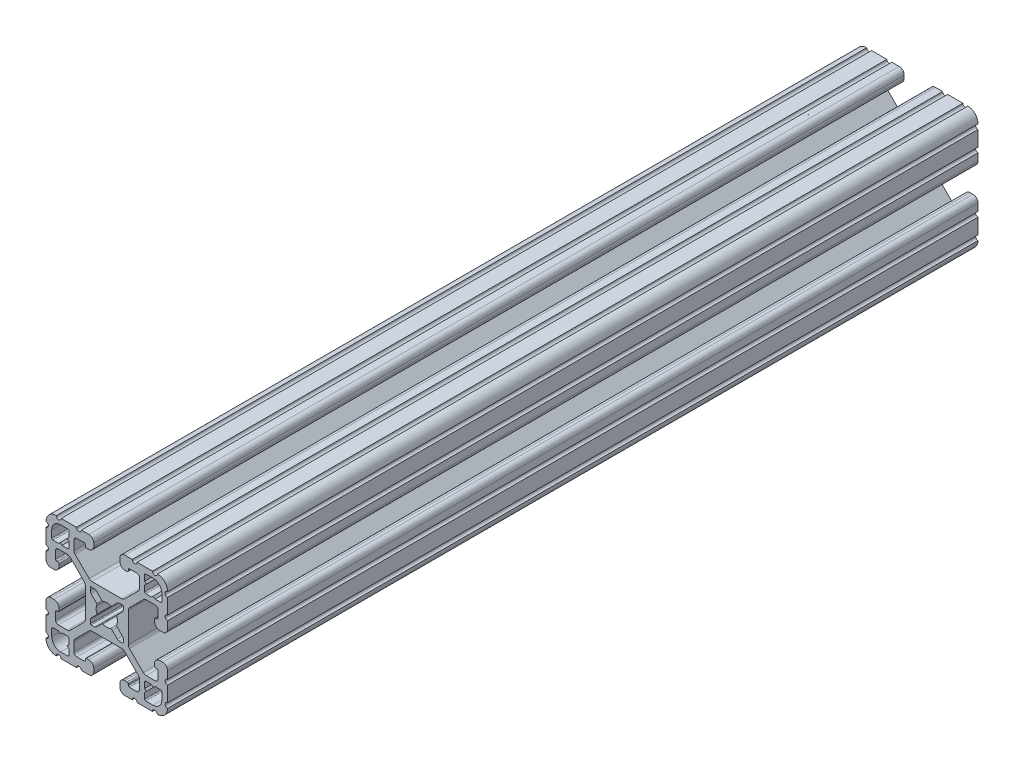
from build123d import *

# Parameters (mm, degrees)
EXTRUDE1_DEPTH = 254


with BuildPart() as part:
    # Sketch1 → Extrude1 (new body)
    with BuildSketch(Plane.XY):
        with BuildLine():
            Line((6.349777007, -14.984831919), (5.653061318, -14.984831848))
            ThreePointArc((5.653061318, -14.984831848), (4.539002167, -15.446080098), (4.077754017, -16.560139291))
            Line((4.077754017, -16.560139291), (4.077753935, -17.474692556))
            ThreePointArc((4.077753935, -17.474692556), (4.539002158, -18.588751741), (5.653061362, -19.049999918))
            Line((5.653061362, -19.049999918), (7.975599859, -19.05))
            ThreePointArc((7.975599859, -19.05), (8.737599929, -18.288), (9.4996, -19.05))
            Line((9.4996, -19.05), (14.298091988, -19.05))
            ThreePointArc((14.298091988, -19.05), (15.05987163, -18.288000032), (15.822092002, -19.049559142))
            ThreePointArc((15.822092002, -19.049559142), (18.110316678, -18.129769245), (19.049898398, -15.849599993))
            ThreePointArc((19.049898398, -15.849599993), (18.288000002, -15.087549199), (19.05, -14.3256))
            Line((19.05, -14.3256), (19.05, -9.499600141))
            ThreePointArc((19.05, -9.499600141), (18.288, -8.737600071), (19.05, -7.9756))
            Line((19.05, -7.9756), (19.05, -5.653061359))
            ThreePointArc((19.05, -5.653061359), (18.588751763, -4.53900218), (17.474692553, -4.077754017))
            Line((17.474692553, -4.077754017), (16.560139293, -4.077753935))
            ThreePointArc((16.560139293, -4.077753935), (15.446080122, -4.539002143), (14.98483193, -5.653061321))
            Line((14.98483193, -5.653061321), (14.984831848, -6.349776986))
            ThreePointArc((14.984831848, -6.349776986), (15.096428348, -6.619420887), (15.366075744, -6.731008942))
            Line((15.366075744, -6.731008942), (15.696937609, -6.730998691))
            ThreePointArc((15.696937609, -6.730998691), (15.966583472, -6.842585282), (16.078181438, -7.112226438))
            Line((16.078181438, -7.112226438), (16.078207121, -9.396837814))
            ThreePointArc((16.078207121, -9.396837814), (15.817838504, -10.026619018), (15.188068118, -10.287013801))
            Line((15.188068118, -10.287013801), (12.352560476, -10.287103022))
            ThreePointArc((12.352560476, -10.287103022), (11.865894357, -10.190173629), (11.453520834, -9.914153164))
            Line((11.453520834, -9.914153164), (7.114725376, -5.565926641))
            ThreePointArc((7.114725376, -5.565926641), (6.840134749, -5.154247475), (6.7437254, -4.668876499))
            Line((6.7437254, -4.668876499), (6.7437254, 4.641368628))
            ThreePointArc((6.7437254, 4.641368628), (6.840134749, 5.126739605), (7.114725376, 5.53841877))
            Line((7.114725376, 5.53841877), (11.480968187, 9.914152308))
            ThreePointArc((11.480968187, 9.914152308), (11.89334171, 10.190172773), (12.380007829, 10.287102166))
            Line((12.380007829, 10.287102166), (15.188068116, 10.287014567))
            ThreePointArc((15.188068116, 10.287014567), (15.817838279, 10.026619243), (16.078206356, 9.396837815))
            Line((16.078206356, 9.396837815), (16.078181509, 7.1122265))
            ThreePointArc((16.078181509, 7.1122265), (15.966583514, 6.842585324), (15.696937607, 6.730998762))
            Line((15.696937607, 6.730998762), (15.366075744, 6.731009012))
            ThreePointArc((15.366075744, 6.731009012), (15.096428376, 6.619420915), (14.984831919, 6.349777007))
            Line((14.984831919, 6.349777007), (14.984831848, 5.653061318))
            ThreePointArc((14.984831848, 5.653061318), (15.446080098, 4.539002167), (16.560139291, 4.077754017))
            Line((16.560139291, 4.077754017), (17.474692556, 4.077753935))
            ThreePointArc((17.474692556, 4.077753935), (18.588751741, 4.539002158), (19.049999918, 5.653061362))
            Line((19.049999918, 5.653061362), (19.05, 7.975599859))
            ThreePointArc((19.05, 7.975599859), (18.288, 8.737599929), (19.05, 9.4996))
            Line((19.05, 9.4996), (19.05, 14.298091988))
            ThreePointArc((19.05, 14.298091988), (18.288000032, 15.05987163), (19.049559142, 15.822092002))
            ThreePointArc((19.049559142, 15.822092002), (18.129769245, 18.110316678), (15.849599993, 19.049898398))
            ThreePointArc((15.849599993, 19.049898398), (15.087549199, 18.288000002), (14.3256, 19.05))
            Line((14.3256, 19.05), (9.499600141, 19.05))
            ThreePointArc((9.499600141, 19.05), (8.737600071, 18.288), (7.9756, 19.05))
            Line((7.9756, 19.05), (5.653061359, 19.05))
            ThreePointArc((5.653061359, 19.05), (4.53900218, 18.588751763), (4.077754017, 17.474692553))
            Line((4.077754017, 17.474692553), (4.077753935, 16.560139293))
            ThreePointArc((4.077753935, 16.560139293), (4.539002143, 15.446080122), (5.653061321, 14.98483193))
            Line((5.653061321, 14.98483193), (6.349776986, 14.984831848))
            ThreePointArc((6.349776986, 14.984831848), (6.619420887, 15.096428348), (6.731008942, 15.366075744))
            Line((6.731008942, 15.366075744), (6.730998691, 15.696937609))
            ThreePointArc((6.730998691, 15.696937609), (6.842585282, 15.966583472), (7.112226438, 16.078181438))
            Line((7.112226438, 16.078181438), (9.396837814, 16.078207121))
            ThreePointArc((9.396837814, 16.078207121), (10.026619018, 15.817838504), (10.287013801, 15.188068118))
            Line((10.287013801, 15.188068118), (10.287103022, 12.352560476))
            ThreePointArc((10.287103022, 12.352560476), (10.190173629, 11.865894357), (9.914153164, 11.453520834))
            Line((9.914153164, 11.453520834), (5.565926641, 7.114725376))
            ThreePointArc((5.565926641, 7.114725376), (5.154247475, 6.840134749), (4.668876499, 6.7437254))
            Line((4.668876499, 6.7437254), (-4.641368628, 6.7437254))
            ThreePointArc((-4.641368628, 6.7437254), (-5.126739605, 6.840134749), (-5.53841877, 7.114725376))
            Line((-5.53841877, 7.114725376), (-9.914152308, 11.480968187))
            ThreePointArc((-9.914152308, 11.480968187), (-10.190172773, 11.89334171), (-10.287102166, 12.380007829))
            Line((-10.287102166, 12.380007829), (-10.287014567, 15.188068116))
            ThreePointArc((-10.287014567, 15.188068116), (-10.026619243, 15.817838279), (-9.396837815, 16.078206356))
            Line((-9.396837815, 16.078206356), (-7.1122265, 16.078181509))
            ThreePointArc((-7.1122265, 16.078181509), (-6.842585324, 15.966583514), (-6.730998762, 15.696937607))
            Line((-6.730998762, 15.696937607), (-6.731008942, 15.366075744))
            ThreePointArc((-6.731008942, 15.366075744), (-6.619420905, 15.096428366), (-6.349777007, 14.984831919))
            Line((-6.349777007, 14.984831919), (-5.653061318, 14.984831848))
            ThreePointArc((-5.653061318, 14.984831848), (-4.539002167, 15.446080098), (-4.077754017, 16.560139291))
            Line((-4.077754017, 16.560139291), (-4.077753935, 17.474692556))
            ThreePointArc((-4.077753935, 17.474692556), (-4.539002158, 18.588751741), (-5.653061362, 19.049999918))
            Line((-5.653061362, 19.049999918), (-7.975599859, 19.05))
            ThreePointArc((-7.975599859, 19.05), (-8.737599929, 18.288), (-9.4996, 19.05))
            Line((-9.4996, 19.05), (-14.298091988, 19.05))
            ThreePointArc((-14.298091988, 19.05), (-15.05987163, 18.288000032), (-15.822092002, 19.049559142))
            ThreePointArc((-15.822092002, 19.049559142), (-18.110316678, 18.129769245), (-19.049898398, 15.849599993))
            ThreePointArc((-19.049898398, 15.849599993), (-18.288000002, 15.087549199), (-19.05, 14.3256))
            Line((-19.05, 14.3256), (-19.05, 9.499600141))
            ThreePointArc((-19.05, 9.499600141), (-18.288, 8.737600071), (-19.05, 7.9756))
            Line((-19.05, 7.9756), (-19.05, 5.653061359))
            ThreePointArc((-19.05, 5.653061359), (-18.588751763, 4.53900218), (-17.474692553, 4.077754017))
            Line((-17.474692553, 4.077754017), (-16.560139293, 4.077753935))
            ThreePointArc((-16.560139293, 4.077753935), (-15.446080122, 4.539002143), (-14.98483193, 5.653061321))
            Line((-14.98483193, 5.653061321), (-14.984831848, 6.349776986))
            ThreePointArc((-14.984831848, 6.349776986), (-15.096428348, 6.619420887), (-15.366075744, 6.731008942))
            Line((-15.366075744, 6.731008942), (-15.696937609, 6.730998691))
            ThreePointArc((-15.696937609, 6.730998691), (-15.966583472, 6.842585283), (-16.078181438, 7.112226438))
            Line((-16.078181438, 7.112226438), (-16.078207121, 9.396837814))
            ThreePointArc((-16.078207121, 9.396837814), (-15.817838504, 10.026619018), (-15.188068118, 10.287013802))
            Line((-15.188068118, 10.287013802), (-12.352560476, 10.287103022))
            ThreePointArc((-12.352560476, 10.287103022), (-11.865894357, 10.190173629), (-11.453520834, 9.914153164))
            Line((-11.453520834, 9.914153164), (-7.114725376, 5.565926641))
            ThreePointArc((-7.114725376, 5.565926641), (-6.840134749, 5.154247475), (-6.7437254, 4.668876499))
            Line((-6.7437254, 4.668876499), (-6.7437254, -4.641368628))
            ThreePointArc((-6.7437254, -4.641368628), (-6.840134749, -5.126739605), (-7.114725376, -5.53841877))
            Line((-7.114725376, -5.53841877), (-11.480968187, -9.914152308))
            ThreePointArc((-11.480968187, -9.914152308), (-11.89334171, -10.190172773), (-12.380007829, -10.287102166))
            Line((-12.380007829, -10.287102166), (-15.188068116, -10.287014567))
            ThreePointArc((-15.188068116, -10.287014567), (-15.817838279, -10.026619243), (-16.078206356, -9.396837815))
            Line((-16.078206356, -9.396837815), (-16.078181509, -7.1122265))
            ThreePointArc((-16.078181509, -7.1122265), (-15.966583514, -6.842585324), (-15.696937607, -6.730998762))
            Line((-15.696937607, -6.730998762), (-15.366075744, -6.731009012))
            ThreePointArc((-15.366075744, -6.731009012), (-15.096428376, -6.619420915), (-14.984831919, -6.349777007))
            Line((-14.984831919, -6.349777007), (-14.984831848, -5.653061318))
            ThreePointArc((-14.984831848, -5.653061318), (-15.446080098, -4.539002167), (-16.560139291, -4.077754017))
            Line((-16.560139291, -4.077754017), (-17.474692556, -4.077753935))
            ThreePointArc((-17.474692556, -4.077753935), (-18.588751741, -4.539002158), (-19.049999918, -5.653061362))
            Line((-19.049999918, -5.653061362), (-19.05, -7.975599859))
            ThreePointArc((-19.05, -7.975599859), (-18.288, -8.737599929), (-19.05, -9.4996))
            Line((-19.05, -9.4996), (-19.05, -14.298091988))
            ThreePointArc((-19.05, -14.298091988), (-18.288000032, -15.05987163), (-19.049559142, -15.822092002))
            ThreePointArc((-19.049559142, -15.822092002), (-18.129769245, -18.110316678), (-15.849599993, -19.049898398))
            ThreePointArc((-15.849599993, -19.049898398), (-15.087549199, -18.288000002), (-14.3256, -19.05))
            Line((-14.3256, -19.05), (-9.499600141, -19.05))
            ThreePointArc((-9.499600141, -19.05), (-8.737600071, -18.288), (-7.9756, -19.05))
            Line((-7.9756, -19.05), (-5.653061359, -19.05))
            ThreePointArc((-5.653061359, -19.05), (-4.53900218, -18.588751763), (-4.077754017, -17.474692553))
            Line((-4.077754017, -17.474692553), (-4.077753935, -16.560139293))
            ThreePointArc((-4.077753935, -16.560139293), (-4.539002143, -15.446080122), (-5.653061321, -14.98483193))
            Line((-5.653061321, -14.98483193), (-6.349776986, -14.984831848))
            ThreePointArc((-6.349776986, -14.984831848), (-6.619420887, -15.096428348), (-6.731008942, -15.366075744))
            Line((-6.731008942, -15.366075744), (-6.730998691, -15.696937609))
            ThreePointArc((-6.730998691, -15.696937609), (-6.842585282, -15.966583472), (-7.112226438, -16.078181438))
            Line((-7.112226438, -16.078181438), (-9.396837814, -16.078207121))
            ThreePointArc((-9.396837814, -16.078207121), (-10.026619018, -15.817838504), (-10.287013801, -15.188068118))
            Line((-10.287013801, -15.188068118), (-10.287103022, -12.352560476))
            ThreePointArc((-10.287103022, -12.352560476), (-10.190173629, -11.865894357), (-9.914153164, -11.453520834))
            Line((-9.914153164, -11.453520834), (-5.565926641, -7.114725376))
            ThreePointArc((-5.565926641, -7.114725376), (-5.154247475, -6.840134749), (-4.668876499, -6.7437254))
            Line((-4.668876499, -6.7437254), (4.641368628, -6.7437254))
            ThreePointArc((4.641368628, -6.7437254), (5.126739605, -6.840134749), (5.53841877, -7.114725376))
            Line((5.53841877, -7.114725376), (9.914152308, -11.480968187))
            ThreePointArc((9.914152308, -11.480968187), (10.190172773, -11.89334171), (10.287102166, -12.380007829))
            Line((10.287102166, -12.380007829), (10.287014567, -15.188068116))
            ThreePointArc((10.287014567, -15.188068116), (10.026619243, -15.817838279), (9.396837815, -16.078206356))
            Line((9.396837815, -16.078206356), (7.1122265, -16.078181509))
            ThreePointArc((7.1122265, -16.078181509), (6.842585324, -15.966583514), (6.730998762, -15.696937607))
            Line((6.730998762, -15.696937607), (6.731008942, -15.366075744))
            ThreePointArc((6.731008942, -15.366075744), (6.619420905, -15.096428366), (6.349777007, -14.984831919))
        make_face()
        with BuildLine():
            Line((1.582347442, 3.198793543), (3.292097227, 4.908543328))
            ThreePointArc((3.292097227, 4.908543328), (3.580509584, 5.101254304), (3.920715155, 5.1689254))
            Line((3.920715155, 5.1689254), (4.9149254, 5.1689254))
            ThreePointArc((4.9149254, 5.1689254), (5.094530522, 5.094530522), (5.1689254, 4.9149254))
            Line((5.1689254, 4.9149254), (5.1689254, 3.920715155))
            ThreePointArc((5.1689254, 3.920715155), (5.101254304, 3.580509584), (4.908543328, 3.292097227))
            Line((4.908543328, 3.292097227), (3.198793543, 1.582347442))
            ThreePointArc((3.198793543, 1.582347442), (3.095711236, 1.393016011), (3.111879183, 1.178048687))
            ThreePointArc((3.111879183, 1.178048687), (3.3274, 0), (3.111879183, -1.178048687))
            ThreePointArc((3.111879183, -1.178048687), (3.095711236, -1.393016011), (3.198793543, -1.582347442))
            Line((3.198793543, -1.582347442), (4.908543328, -3.292097227))
            ThreePointArc((4.908543328, -3.292097227), (5.101254304, -3.580509584), (5.1689254, -3.920715155))
            Line((5.1689254, -3.920715155), (5.1689254, -4.9149254))
            ThreePointArc((5.1689254, -4.9149254), (5.094530522, -5.094530522), (4.9149254, -5.1689254))
            Line((4.9149254, -5.1689254), (3.920715155, -5.1689254))
            ThreePointArc((3.920715155, -5.1689254), (3.580509584, -5.101254304), (3.292097227, -4.908543328))
            Line((3.292097227, -4.908543328), (1.582347442, -3.198793543))
            ThreePointArc((1.582347442, -3.198793543), (1.393016011, -3.095711236), (1.178048687, -3.111879183))
            ThreePointArc((1.178048687, -3.111879183), (0, -3.3274), (-1.178048687, -3.111879183))
            ThreePointArc((-1.178048687, -3.111879183), (-1.393016011, -3.095711236), (-1.582347442, -3.198793543))
            Line((-1.582347442, -3.198793543), (-3.292097227, -4.908543328))
            ThreePointArc((-3.292097227, -4.908543328), (-3.580509584, -5.101254304), (-3.920715155, -5.1689254))
            Line((-3.920715155, -5.1689254), (-4.9149254, -5.1689254))
            ThreePointArc((-4.9149254, -5.1689254), (-5.094530522, -5.094530522), (-5.1689254, -4.9149254))
            Line((-5.1689254, -4.9149254), (-5.1689254, -3.920715155))
            ThreePointArc((-5.1689254, -3.920715155), (-5.101254304, -3.580509584), (-4.908543328, -3.292097227))
            Line((-4.908543328, -3.292097227), (-3.198793543, -1.582347442))
            ThreePointArc((-3.198793543, -1.582347442), (-3.095711236, -1.393016011), (-3.111879183, -1.178048687))
            ThreePointArc((-3.111879183, -1.178048687), (-3.3274, 0), (-3.111879183, 1.178048687))
            ThreePointArc((-3.111879183, 1.178048687), (-3.095711236, 1.393016011), (-3.198793543, 1.582347442))
            Line((-3.198793543, 1.582347442), (-4.908543328, 3.292097227))
            ThreePointArc((-4.908543328, 3.292097227), (-5.101254304, 3.580509584), (-5.1689254, 3.920715155))
            Line((-5.1689254, 3.920715155), (-5.1689254, 4.9149254))
            ThreePointArc((-5.1689254, 4.9149254), (-5.094530522, 5.094530522), (-4.9149254, 5.1689254))
            Line((-4.9149254, 5.1689254), (-3.920715155, 5.1689254))
            ThreePointArc((-3.920715155, 5.1689254), (-3.580509584, 5.101254304), (-3.292097227, 4.908543328))
            Line((-3.292097227, 4.908543328), (-1.582347442, 3.198793543))
            ThreePointArc((-1.582347442, 3.198793543), (-1.393016011, 3.095711236), (-1.178048687, 3.111879183))
            ThreePointArc((-1.178048687, 3.111879183), (0, 3.3274), (1.178048687, 3.111879183))
            ThreePointArc((1.178048687, 3.111879183), (1.393016011, 3.095711236), (1.582347442, 3.198793543))
        make_face(mode=Mode.SUBTRACT)
        with BuildLine():
            Line((-11.8669054, 14.019430433), (-11.8669054, 12.24788))
            ThreePointArc((-11.8669054, 12.24788), (-11.978497716, 11.978472316), (-12.2479054, 11.86688))
            Line((-12.2479054, 11.86688), (-14.019455833, 11.86688))
            ThreePointArc((-14.019455833, 11.86688), (-14.020427836, 11.867073341), (-14.021251865, 11.867623929))
            Line((-14.021251865, 11.867623929), (-14.557512425, 12.403872831))
            ThreePointArc((-14.557512425, 12.403872831), (-14.559308484, 12.404616761), (-14.561104527, 12.403872792))
            Line((-14.561104527, 12.403872792), (-15.097341694, 11.867623968))
            ThreePointArc((-15.097341694, 11.867623968), (-15.098165736, 11.867073351), (-15.099137765, 11.86688))
            Line((-15.099137765, 11.86688), (-16.8707054, 11.86688))
            ThreePointArc((-16.8707054, 11.86688), (-17.140113084, 11.978472316), (-17.2517054, 12.24788))
            Line((-17.2517054, 12.24788), (-17.2517054, 14.45768))
            ThreePointArc((-17.2517054, 14.45768), (-16.433361747, 16.433336347), (-14.4577054, 17.25168))
            Line((-14.4577054, 17.25168), (-12.2479054, 17.25168))
            ThreePointArc((-12.2479054, 17.25168), (-11.978497716, 17.140087684), (-11.8669054, 16.87068))
            Line((-11.8669054, 16.87068), (-11.8669054, 15.099112365))
            ThreePointArc((-11.8669054, 15.099112365), (-11.867098751, 15.098140336), (-11.867649368, 15.097316294))
            Line((-11.867649368, 15.097316294), (-12.403898192, 14.561079127))
            ThreePointArc((-12.403898192, 14.561079127), (-12.40464216, 14.559283084), (-12.403898231, 14.557487025))
            Line((-12.403898231, 14.557487025), (-11.867649329, 14.021226465))
            ThreePointArc((-11.867649329, 14.021226465), (-11.867098741, 14.020402437), (-11.8669054, 14.019430433))
        make_face(mode=Mode.SUBTRACT)
        with BuildLine():
            Line((-14.019430433, -11.8669054), (-12.24788, -11.8669054))
            ThreePointArc((-12.24788, -11.8669054), (-11.978472316, -11.978497716), (-11.86688, -12.2479054))
            Line((-11.86688, -12.2479054), (-11.86688, -14.019455833))
            ThreePointArc((-11.86688, -14.019455833), (-11.867073341, -14.020427836), (-11.867623929, -14.021251865))
            Line((-11.867623929, -14.021251865), (-12.403872831, -14.557512425))
            ThreePointArc((-12.403872831, -14.557512425), (-12.404616761, -14.559308484), (-12.403872792, -14.561104527))
            Line((-12.403872792, -14.561104527), (-11.867623968, -15.097341694))
            ThreePointArc((-11.867623968, -15.097341694), (-11.867073351, -15.098165736), (-11.86688, -15.099137765))
            Line((-11.86688, -15.099137765), (-11.86688, -16.8707054))
            ThreePointArc((-11.86688, -16.8707054), (-11.978472316, -17.140113083), (-12.24788, -17.2517054))
            Line((-12.24788, -17.2517054), (-14.45768, -17.2517054))
            ThreePointArc((-14.45768, -17.2517054), (-16.433336347, -16.433361746), (-17.25168, -14.4577054))
            Line((-17.25168, -14.4577054), (-17.25168, -12.2479054))
            ThreePointArc((-17.25168, -12.2479054), (-17.140087684, -11.978497716), (-16.87068, -11.8669054))
            Line((-16.87068, -11.8669054), (-15.099112365, -11.8669054))
            ThreePointArc((-15.099112365, -11.8669054), (-15.098140336, -11.867098751), (-15.097316294, -11.867649368))
            Line((-15.097316294, -11.867649368), (-14.561079127, -12.403898192))
            ThreePointArc((-14.561079127, -12.403898192), (-14.559283084, -12.40464216), (-14.557487025, -12.403898231))
            Line((-14.557487025, -12.403898231), (-14.021226465, -11.867649329))
            ThreePointArc((-14.021226465, -11.867649329), (-14.020402437, -11.867098741), (-14.019430433, -11.8669054))
        make_face(mode=Mode.SUBTRACT)
        with BuildLine():
            Line((11.8669054, -14.019430433), (11.8669054, -12.24788))
            ThreePointArc((11.8669054, -12.24788), (11.978497716, -11.978472316), (12.2479054, -11.86688))
            Line((12.2479054, -11.86688), (14.019455833, -11.86688))
            ThreePointArc((14.019455833, -11.86688), (14.020427836, -11.867073341), (14.021251865, -11.867623929))
            Line((14.021251865, -11.867623929), (14.557512425, -12.403872831))
            ThreePointArc((14.557512425, -12.403872831), (14.559308484, -12.404616761), (14.561104527, -12.403872792))
            Line((14.561104527, -12.403872792), (15.097341694, -11.867623968))
            ThreePointArc((15.097341694, -11.867623968), (15.098165736, -11.867073351), (15.099137765, -11.86688))
            Line((15.099137765, -11.86688), (16.8707054, -11.86688))
            ThreePointArc((16.8707054, -11.86688), (17.140113084, -11.978472316), (17.2517054, -12.24788))
            Line((17.2517054, -12.24788), (17.2517054, -14.45768))
            ThreePointArc((17.2517054, -14.45768), (16.433361747, -16.433336347), (14.4577054, -17.25168))
            Line((14.4577054, -17.25168), (12.2479054, -17.25168))
            ThreePointArc((12.2479054, -17.25168), (11.978497716, -17.140087684), (11.8669054, -16.87068))
            Line((11.8669054, -16.87068), (11.8669054, -15.099112365))
            ThreePointArc((11.8669054, -15.099112365), (11.867098751, -15.098140336), (11.867649368, -15.097316294))
            Line((11.867649368, -15.097316294), (12.403898192, -14.561079127))
            ThreePointArc((12.403898192, -14.561079127), (12.40464216, -14.559283084), (12.403898231, -14.557487025))
            Line((12.403898231, -14.557487025), (11.867649329, -14.021226465))
            ThreePointArc((11.867649329, -14.021226465), (11.867098741, -14.020402436), (11.8669054, -14.019430433))
        make_face(mode=Mode.SUBTRACT)
        with BuildLine():
            Line((14.019430433, 11.8669054), (12.24788, 11.8669054))
            ThreePointArc((12.24788, 11.8669054), (11.978472316, 11.978497716), (11.86688, 12.2479054))
            Line((11.86688, 12.2479054), (11.86688, 14.019455833))
            ThreePointArc((11.86688, 14.019455833), (11.867073341, 14.020427836), (11.867623929, 14.021251865))
            Line((11.867623929, 14.021251865), (12.403872831, 14.557512425))
            ThreePointArc((12.403872831, 14.557512425), (12.404616761, 14.559308484), (12.403872792, 14.561104527))
            Line((12.403872792, 14.561104527), (11.867623968, 15.097341694))
            ThreePointArc((11.867623968, 15.097341694), (11.867073351, 15.098165736), (11.86688, 15.099137765))
            Line((11.86688, 15.099137765), (11.86688, 16.8707054))
            ThreePointArc((11.86688, 16.8707054), (11.978472316, 17.140113084), (12.24788, 17.2517054))
            Line((12.24788, 17.2517054), (14.45768, 17.2517054))
            ThreePointArc((14.45768, 17.2517054), (16.433336347, 16.433361747), (17.25168, 14.4577054))
            Line((17.25168, 14.4577054), (17.25168, 12.2479054))
            ThreePointArc((17.25168, 12.2479054), (17.140087684, 11.978497716), (16.87068, 11.8669054))
            Line((16.87068, 11.8669054), (15.099112365, 11.8669054))
            ThreePointArc((15.099112365, 11.8669054), (15.098140336, 11.867098751), (15.097316294, 11.867649368))
            Line((15.097316294, 11.867649368), (14.561079127, 12.403898192))
            ThreePointArc((14.561079127, 12.403898192), (14.559283084, 12.404642161), (14.557487025, 12.403898231))
            Line((14.557487025, 12.403898231), (14.021226465, 11.867649329))
            ThreePointArc((14.021226465, 11.867649329), (14.020402436, 11.867098741), (14.019430433, 11.8669054))
        make_face(mode=Mode.SUBTRACT)
    extrude(amount=-EXTRUDE1_DEPTH)


solid = part.part
